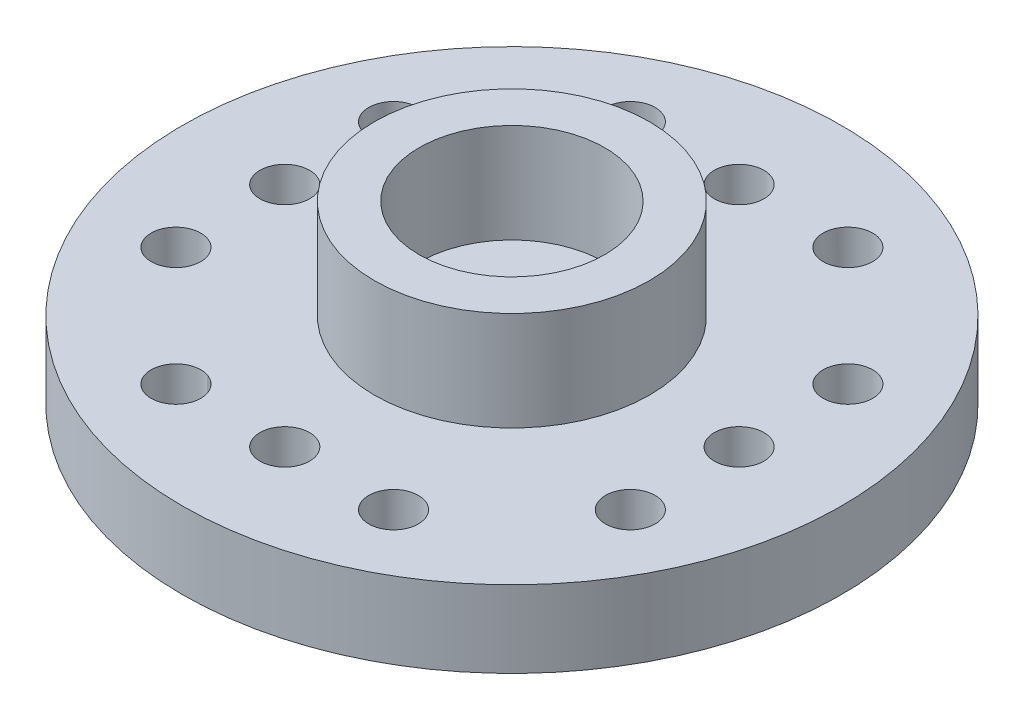
from build123d import *

# Parameters (mm, degrees)
SKETCH_1_R          = 10.3
EXTRUDE_1_DEPTH     = 2.4
SKETCH_2_R          = 4.3
SKETCH_2_R_2        = 2.9
EXTRUDE_2_DEPTH     = 3.1
SKETCH_3_R          = 0.775
CUT_EXTRUDE_1_DEPTH = 2.4
CUT_EXTRUDE_2_REACH = 7.5
SKETCH_4_R          = 1.4


with BuildPart() as part:
    # 草图1 → 凸台-拉伸1 (new body)
    with BuildSketch(Plane(origin=(0, 0, 0), x_dir=(1, 0, 0), z_dir=(0, 1, 0))):
        Circle(SKETCH_1_R)
    extrude(amount=EXTRUDE_1_DEPTH)

    # 草图2 → 凸台-拉伸2 (add)
    with BuildSketch(Plane(origin=(0, 2.4, 0), x_dir=(1, 0, 0), z_dir=(0, 1, 0))):
        Circle(SKETCH_2_R)
        Circle(SKETCH_2_R_2, mode=Mode.SUBTRACT)
    extrude(amount=EXTRUDE_2_DEPTH)

    # 草图3 → 切除-拉伸1 (cut)
    with BuildSketch(Plane.XZ):
        with Locations((0, 7.1)):
            Circle(SKETCH_3_R)
        with BuildLine():
            ThreePointArc((3.009055484, 6.430830825), (3.066525057, 6.403625854), (3.123748696, 6.375907315))
            ThreePointArc((3.123748696, 6.375907315), (3.734726327, 7.798987329), (3.009055484, 6.430830825))
        make_face()
        with BuildLine():
            ThreePointArc((-6.430830825, 3.009055484), (-6.403625854, 3.066525057), (-6.375907315, 3.123748696))
            ThreePointArc((-6.375907315, 3.123748696), (-7.798987329, 3.734726327), (-6.430830825, 3.009055484))
        make_face()
        with Locations((7.1, 3.4)):
            Circle(SKETCH_3_R)
        with Locations((-7.1, 0)):
            Circle(SKETCH_3_R)
        with Locations((7.1, 0)):
            Circle(SKETCH_3_R)
        with Locations((0, -7.1)):
            Circle(SKETCH_3_R)
        with Locations((3.4, -7.1)):
            Circle(SKETCH_3_R)
    cut_extrude_1 = extrude(amount=-CUT_EXTRUDE_1_DEPTH, mode=Mode.SUBTRACT)

    # 镜向1: 切除-拉伸1 across plane
    add(cut_extrude_1.mirror(Plane(origin=(0, 0, 0), x_dir=(0, 0, 1), z_dir=(1, 0, 0))), mode=Mode.SUBTRACT)

    # 镜向2: 切除-拉伸1 across plane
    add(cut_extrude_1.mirror(Plane.XY), mode=Mode.SUBTRACT)

    # 草图4 → 切除-拉伸2 (cut, up to next)
    with BuildSketch(Plane.XZ, mode=Mode.PRIVATE) as cut_extrude_2_sk1:
        Circle(SKETCH_4_R)
    cut_extrude_2_tool1 = extrude(cut_extrude_2_sk1.sketch, amount=-CUT_EXTRUDE_2_REACH, mode=Mode.PRIVATE) & part.part
    add(cut_extrude_2_tool1.solids().sort_by_distance((0, 0, 0))[0], mode=Mode.SUBTRACT)


solid = part.part
